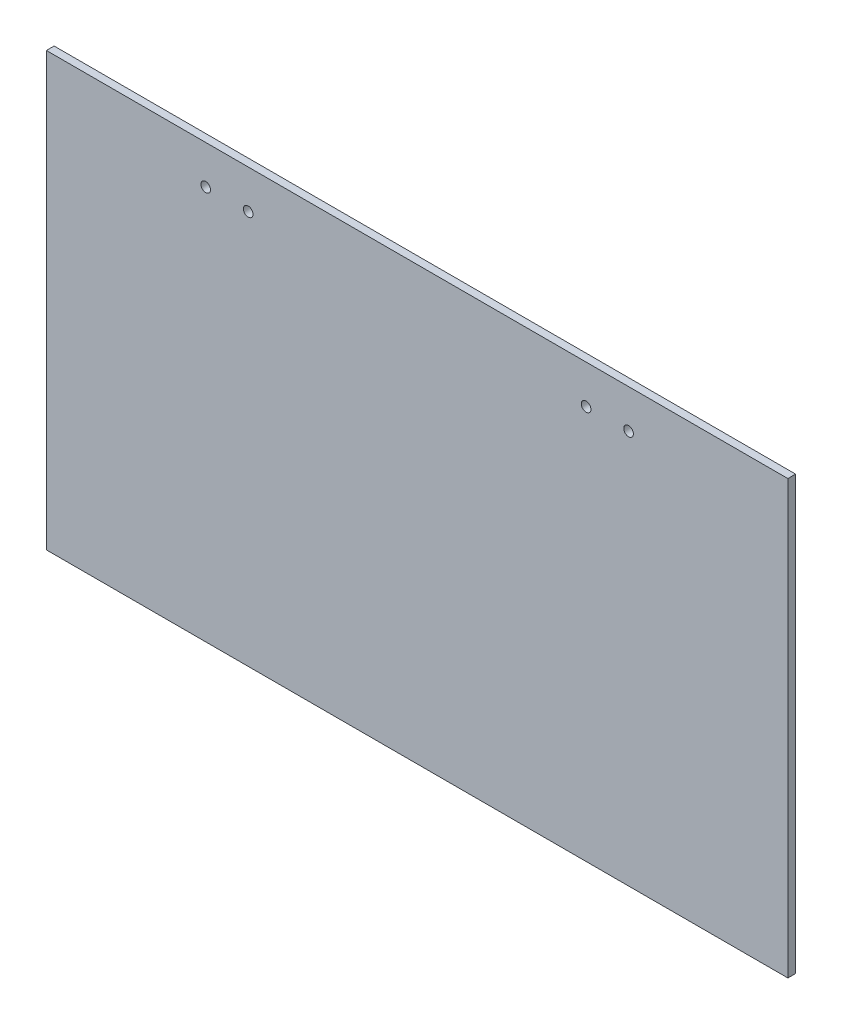
from build123d import *

# Parameters (mm, degrees)
SKETCH1_W           = 304.8
SKETCH1_H           = 177.8
BOSS_EXTRUDE1_DEPTH = 3.175
SKETCH2_R           = 1.984375
CUT_EXTRUDE1_DEPTH  = 4.175


with BuildPart() as part:
    # Sketch1 → Boss-Extrude1 (new body)
    with BuildSketch(Plane.XY):
        Rectangle(SKETCH1_W, SKETCH1_H)
    extrude(amount=BOSS_EXTRUDE1_DEPTH)

    # Sketch2 → Cut-Extrude1 (cut, through all)
    with BuildSketch(Plane.XY.offset(3.175)):
        with Locations((-86.915625, 73.025)):
            Circle(SKETCH2_R)
        with Locations((-69.453125, 73.025)):
            Circle(SKETCH2_R)
        with Locations((69.453125, 73.025)):
            Circle(SKETCH2_R)
        with Locations((86.915625, 73.025)):
            Circle(SKETCH2_R)
    extrude(amount=-CUT_EXTRUDE1_DEPTH, mode=Mode.SUBTRACT)


solid = part.part
